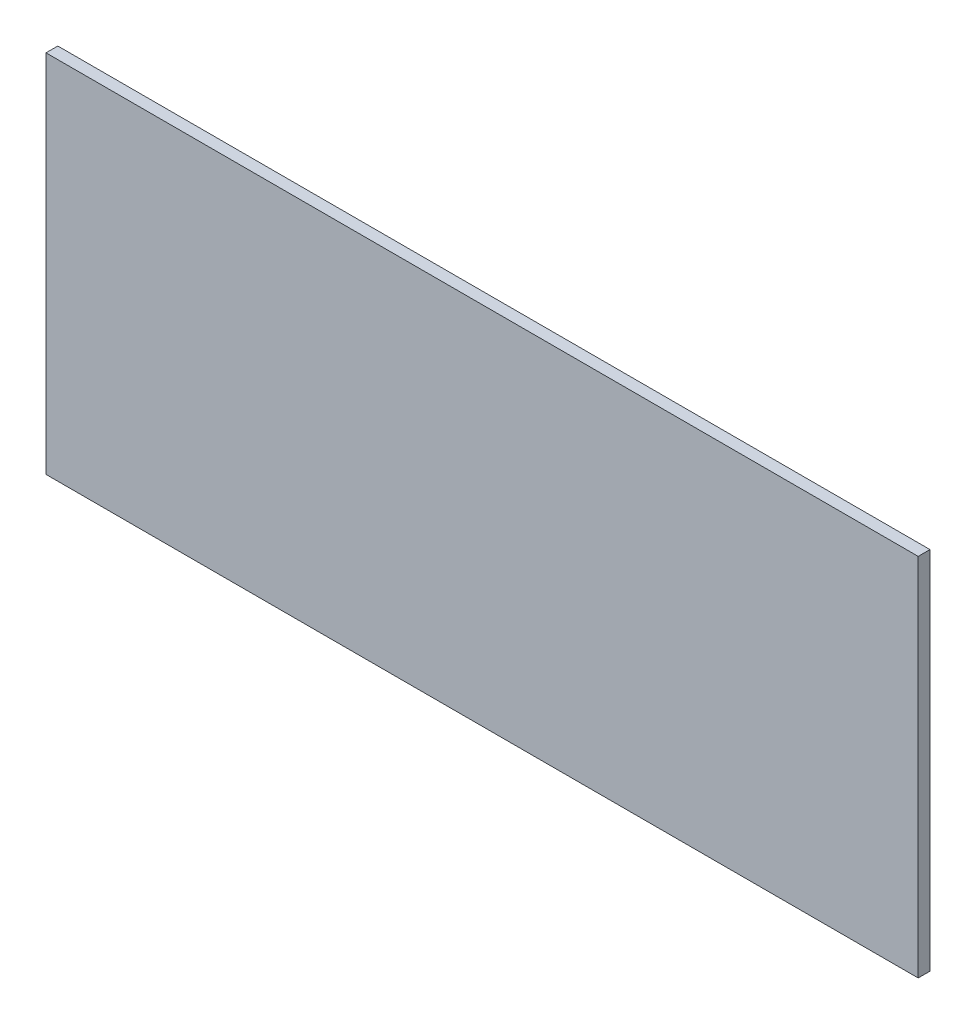
from build123d import *

# Parameters (mm, degrees)
SKETCH1_W           = 112.268
SKETCH1_H           = 47
BOSS_EXTRUDE1_DEPTH = 1.51892


with BuildPart() as part:
    # Sketch1 → Boss-Extrude1 (new body)
    with BuildSketch(Plane.XY):
        with Locations((56.134, 23.5)):
            Rectangle(SKETCH1_W, SKETCH1_H)
    extrude(amount=BOSS_EXTRUDE1_DEPTH)


solid = part.part
